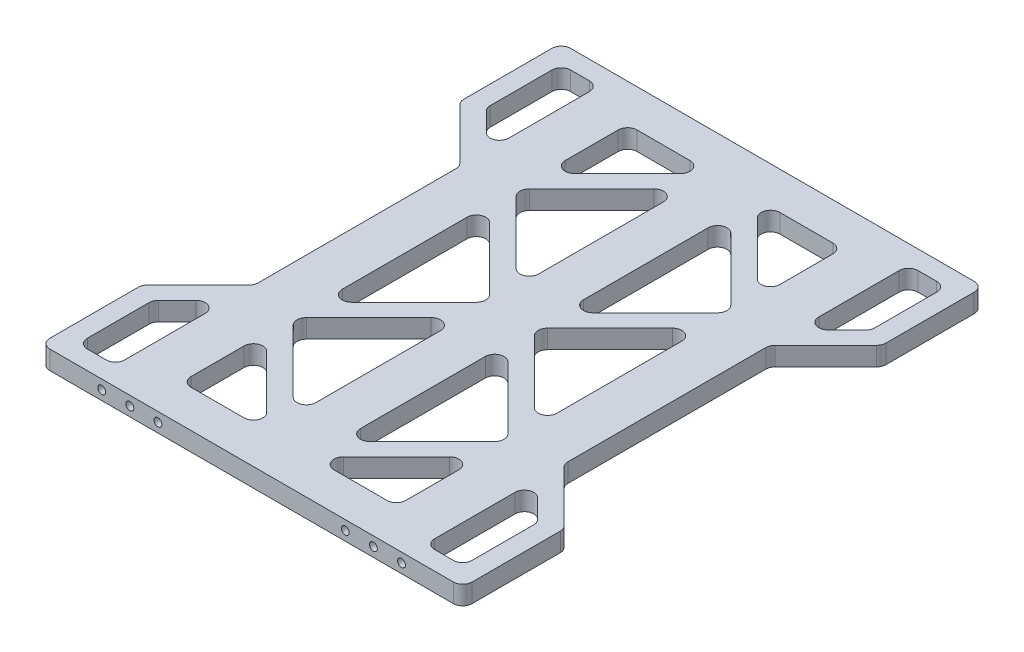
from build123d import *

# Parameters (mm, degrees)
BOSS_EXTRUDE1_DEPTH            = 5
FILLET1_R                      = 5
M5X0_8_TAPPED_HOLE1_AT_2_COUNT = 2
M5X0_8_TAPPED_HOLE1_AT_2_PITCH = 15
M5X0_8_TAPPED_HOLE1_AT_3_COUNT = 2
M5X0_8_TAPPED_HOLE1_AT_3_PITCH = 30
M5X0_8_TAPPED_HOLE1_AT_4_COUNT = 2
M5X0_8_TAPPED_HOLE1_AT_4_PITCH = 130
M5X0_8_TAPPED_HOLE1_AT_5_COUNT = 2
M5X0_8_TAPPED_HOLE1_AT_5_PITCH = 145
M5X0_8_TAPPED_HOLE1_AT_6_COUNT = 2
M5X0_8_TAPPED_HOLE1_AT_6_PITCH = 160


with BuildPart() as part:
    # Sketch1 → Boss-Extrude1 (new body, symmetric)
    with BuildSketch(Plane(origin=(0, 0, 0), x_dir=(1, 0, 0), z_dir=(0, 1, 0))):
        Polygon((-112.7, 139), (112.7, 139), (112.7, 84.857864376), (82.7, 54.857864376), (82.7, -54.857864376), (112.7, -84.857864376), (112.7, -139), (-112.7, -139), (-112.7, -84.857864376), (-82.7, -54.857864376), (-82.7, 54.857864376), (-112.7, 84.857864376), align=None)
        Polygon((11.942135624, 104.857864376), (57.3, 59.5), (11.942135624, 14.142135624), align=None, mode=Mode.SUBTRACT)
        Polygon((11.942135624, 119), (57.3, 119), (57.3, 73.642135624), align=None, mode=Mode.SUBTRACT)
        Polygon((82.7, 129), (102.7, 129), (102.7, 89), (82.7, 69), align=None, mode=Mode.SUBTRACT)
        Polygon((57.3, 45.357864376), (11.942135624, 0), (57.3, -45.357864376), align=None, mode=Mode.SUBTRACT)
        Polygon((102.7, -89), (82.7, -69), (82.7, -129), (102.7, -129), align=None, mode=Mode.SUBTRACT)
        Polygon((57.3, -59.5), (11.942135624, -14.142135624), (11.942135624, -104.857864376), align=None, mode=Mode.SUBTRACT)
        Polygon((57.3, -119), (57.3, -73.642135624), (11.942135624, -119), align=None, mode=Mode.SUBTRACT)
        Polygon((-11.942135624, -119), (-57.3, -119), (-57.3, -73.642135624), align=None, mode=Mode.SUBTRACT)
        Polygon((-11.942135624, -14.142135624), (-11.942135624, -104.857864376), (-57.3, -59.5), align=None, mode=Mode.SUBTRACT)
        Polygon((-57.3, -45.357864376), (-11.942135624, 0), (-57.3, 45.357864376), align=None, mode=Mode.SUBTRACT)
        Polygon((-102.7, -129), (-102.7, -89), (-82.7, -69), (-82.7, -129), align=None, mode=Mode.SUBTRACT)
        Polygon((-11.942135624, 14.142135624), (-11.942135624, 104.857864376), (-57.3, 59.5), align=None, mode=Mode.SUBTRACT)
        Polygon((-82.7, 69), (-82.7, 129), (-102.7, 129), (-102.7, 89), align=None, mode=Mode.SUBTRACT)
        Polygon((-57.3, 73.642135624), (-11.942135624, 119), (-57.3, 119), align=None, mode=Mode.SUBTRACT)
    extrude(amount=BOSS_EXTRUDE1_DEPTH, both=True)

    # Fillet1
    fillet1_edges = [part.edges().sort_by_distance(p)[0] for p in [
        (-57.3, 0, -59.5),
        (-11.942135624, 0, -14.142135624),
        (-11.942135624, 0, -104.857864376),
        (-11.942135624, 0, 0),
        (-57.3, 0, -45.357864376),
        (-57.3, 0, 45.357864376),
        (-11.942135624, 0, -119),
        (-57.3, 0, -119),
        (-57.3, 0, -73.642135624),
        (-11.942135624, 0, 119),
        (-57.3, 0, 73.642135624),
        (-57.3, 0, 119),
        (-11.942135624, 0, 14.142135624),
        (-57.3, 0, 59.5),
        (-11.942135624, 0, 104.857864376),
        (-102.7, 0, 129),
        (-82.7, 0, 129),
        (-82.7, 0, 69),
        (-102.7, 0, 89),
        (-102.7, 0, -89),
        (-82.7, 0, -69),
        (-82.7, 0, -129),
        (-102.7, 0, -129),
        (112.7, 0, 84.857864376),
        (112.7, 0, 139),
        (-112.7, 0, 139),
        (-112.7, 0, 84.857864376),
        (-82.7, 0, 54.857864376),
        (-82.7, 0, -54.857864376),
        (-112.7, 0, -84.857864376),
        (-112.7, 0, -139),
        (112.7, 0, -139),
        (112.7, 0, -84.857864376),
        (82.7, 0, -54.857864376),
        (82.7, 0, 54.857864376),
        (11.942135624, 0, -104.857864376),
        (11.942135624, 0, -14.142135624),
        (57.3, 0, -59.5),
        (102.7, 0, 129),
        (102.7, 0, 89),
        (82.7, 0, 69),
        (82.7, 0, 129),
        (11.942135624, 0, -119),
        (57.3, 0, -73.642135624),
        (57.3, 0, -119),
        (11.942135624, 0, 104.857864376),
        (57.3, 0, 59.5),
        (11.942135624, 0, 14.142135624),
        (82.7, 0, -69),
        (102.7, 0, -89),
        (102.7, 0, -129),
        (82.7, 0, -129),
        (57.3, 0, 45.357864376),
        (57.3, 0, -45.357864376),
        (11.942135624, 0, 0),
        (11.942135624, 0, 119),
        (57.3, 0, 119),
        (57.3, 0, 73.642135624),
    ]]
    fillet(fillet1_edges, radius=FILLET1_R)

    # Sketch5 → M5x0.8 Tapped Hole1 (revolve, cut)
    with BuildSketch(Plane(origin=(80, 0, -139), x_dir=(0, 1, 0), z_dir=(1, 0, 0))):
        Polygon((0, 0), (0, 13.6618073), (2.1, 12.4), (2.1, 0), align=None)
    m5x0_8_tapped_hole1 = revolve(axis=Axis((80, 0, -145.35), (0, 0, 1)), mode=Mode.SUBTRACT)

    # M5x0.8 Tapped Hole1 at 2: M5x0.8 Tapped Hole1 ×2
    with Locations(*[(-i * M5X0_8_TAPPED_HOLE1_AT_2_PITCH, 0, 0) for i in range(1, M5X0_8_TAPPED_HOLE1_AT_2_COUNT)]):
        add(m5x0_8_tapped_hole1, mode=Mode.SUBTRACT)

    # M5x0.8 Tapped Hole1 at 3: M5x0.8 Tapped Hole1 ×2
    with Locations(*[(-i * M5X0_8_TAPPED_HOLE1_AT_3_PITCH, 0, 0) for i in range(1, M5X0_8_TAPPED_HOLE1_AT_3_COUNT)]):
        add(m5x0_8_tapped_hole1, mode=Mode.SUBTRACT)

    # M5x0.8 Tapped Hole1 at 4: M5x0.8 Tapped Hole1 ×2
    with Locations(*[(-i * M5X0_8_TAPPED_HOLE1_AT_4_PITCH, 0, 0) for i in range(1, M5X0_8_TAPPED_HOLE1_AT_4_COUNT)]):
        add(m5x0_8_tapped_hole1, mode=Mode.SUBTRACT)

    # M5x0.8 Tapped Hole1 at 5: M5x0.8 Tapped Hole1 ×2
    with Locations(*[(-i * M5X0_8_TAPPED_HOLE1_AT_5_PITCH, 0, 0) for i in range(1, M5X0_8_TAPPED_HOLE1_AT_5_COUNT)]):
        add(m5x0_8_tapped_hole1, mode=Mode.SUBTRACT)

    # M5x0.8 Tapped Hole1 at 6: M5x0.8 Tapped Hole1 ×2
    with Locations(*[(-i * M5X0_8_TAPPED_HOLE1_AT_6_PITCH, 0, 0) for i in range(1, M5X0_8_TAPPED_HOLE1_AT_6_COUNT)]):
        add(m5x0_8_tapped_hole1, mode=Mode.SUBTRACT)

    # Mirror1: M5x0.8 Tapped Hole1 across plane
    add(m5x0_8_tapped_hole1.mirror(Plane.XY), mode=Mode.SUBTRACT)

    # Mirror1 copy 1 sketch → Mirror1 copy 1 (revolve, cut)
    with BuildSketch(Plane(origin=(65, 0, 139), x_dir=(0, 1, 0), z_dir=(1, 0, 0))):
        Polygon((0, 0), (0, -13.6618073), (2.1, -12.4), (2.1, 0), align=None)
    revolve(axis=Axis((65, 0, 145.35), (0, 0, 1)), mode=Mode.SUBTRACT)

    # Mirror1 copy 2 sketch → Mirror1 copy 2 (revolve, cut)
    with BuildSketch(Plane(origin=(50, 0, 139), x_dir=(0, 1, 0), z_dir=(1, 0, 0))):
        Polygon((0, 0), (0, -13.6618073), (2.1, -12.4), (2.1, 0), align=None)
    revolve(axis=Axis((50, 0, 145.35), (0, 0, 1)), mode=Mode.SUBTRACT)

    # Mirror1 copy 3 sketch → Mirror1 copy 3 (revolve, cut)
    with BuildSketch(Plane(origin=(-50, 0, 139), x_dir=(0, 1, 0), z_dir=(1, 0, 0))):
        Polygon((0, 0), (0, -13.6618073), (2.1, -12.4), (2.1, 0), align=None)
    revolve(axis=Axis((-50, 0, 145.35), (0, 0, 1)), mode=Mode.SUBTRACT)

    # Mirror1 copy 4 sketch → Mirror1 copy 4 (revolve, cut)
    with BuildSketch(Plane(origin=(-65, 0, 139), x_dir=(0, 1, 0), z_dir=(1, 0, 0))):
        Polygon((0, 0), (0, -13.6618073), (2.1, -12.4), (2.1, 0), align=None)
    revolve(axis=Axis((-65, 0, 145.35), (0, 0, 1)), mode=Mode.SUBTRACT)

    # Mirror1 copy 5 sketch → Mirror1 copy 5 (revolve, cut)
    with BuildSketch(Plane(origin=(-80, 0, 139), x_dir=(0, 1, 0), z_dir=(1, 0, 0))):
        Polygon((0, 0), (0, -13.6618073), (2.1, -12.4), (2.1, 0), align=None)
    revolve(axis=Axis((-80, 0, 145.35), (0, 0, 1)), mode=Mode.SUBTRACT)


solid = part.part
